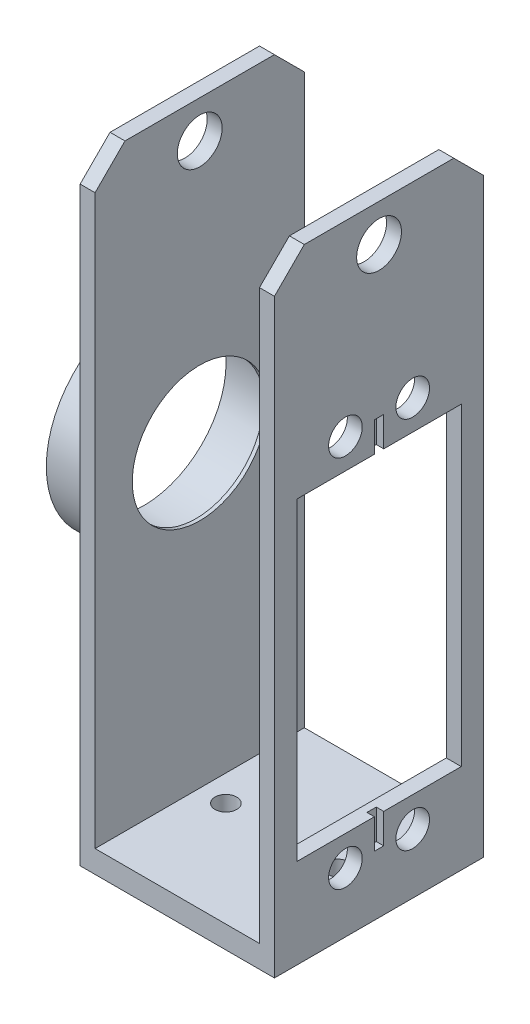
from build123d import *

# Parameters (mm, degrees)
SKETCH1_W               = 22
SKETCH1_H               = 28
BOSS_EXTRUDE1_DEPTH     = 3
SKETCH2_R               = 1.45
CUT_EXTRUDE1_DEPTH      = 4
SKETCH3_W               = 28
SKETCH3_H               = 80
SKETCH3_H_2             = 3
BOSS_EXTRUDE2_DEPTH     = 2
SKETCH4_R               = 2.25
SKETCH4_W               = 22
SKETCH4_H               = 42
CUT_EXTRUDE2_DEPTH      = 10
SKETCH5_R               = 11.025
CUT_EXTRUDE3_DEPTH      = 10
SKETCH6_R               = 11.025
SKETCH6_R_2             = 9.025
BOSS_EXTRUDE3_DEPTH     = 0.5
SKETCH7_R               = 13.025
SKETCH7_R_2             = 11.025
BOSS_EXTRUDE4_DEPTH     = 5.5
SKETCH9_W               = 1.25
SKETCH9_H               = 4
CUT_EXTRUDE5_DEPTH      = 1
SKETCH4_4_R             = 3
CUT_EXTRUDE6_DEPTH      = 30.5
CUT_EXTRUDE6_DEPTH_BACK = 3
CHAMFER1_SIZE           = 4


with BuildPart() as part:
    # Sketch1 → Boss-Extrude1 (new body)
    with BuildSketch(Plane(origin=(0, 0, 0), x_dir=(1, 0, 0), z_dir=(0, 1, 0))):
        Rectangle(SKETCH1_W, SKETCH1_H)
    extrude(amount=BOSS_EXTRUDE1_DEPTH)

    # Sketch2 → Cut-Extrude1 (cut, through all)
    with BuildSketch(Plane.XZ):
        with Locations(Location((-7.5, 0, 0), (0, 0, 270))):  # turned: the seam where the file's is
            Circle(SKETCH2_R)
        with Locations(Location((7.5, 0, 0), (0, 0, 270))):  # turned: the seam where the file's is
            Circle(SKETCH2_R)
    extrude(amount=-CUT_EXTRUDE1_DEPTH, mode=Mode.SUBTRACT)

    # Sketch3 → Boss-Extrude2 (add)
    with BuildSketch(Plane(origin=(11, 0, 0), x_dir=(0, 0, -1), z_dir=(1, 0, 0))):
        with Locations((0, 43)):
            Rectangle(SKETCH3_W, SKETCH3_H)
        with Locations((0, 1.5)):
            Rectangle(SKETCH3_W, SKETCH3_H_2)
    boss_extrude2 = extrude(amount=BOSS_EXTRUDE2_DEPTH)

    # Sketch4 → Cut-Extrude2 (cut)
    with BuildSketch(Plane.ZY.offset(-11)):
        with Locations((-4.5, 8)):
            Circle(SKETCH4_R)
        with Locations((4.5, 8)):
            Circle(SKETCH4_R)
        with Locations((4.5, 58)):
            Circle(SKETCH4_R)
        with Locations((-4.5, 58)):
            Circle(SKETCH4_R)
        with Locations((0, 33)):
            Rectangle(SKETCH4_W, SKETCH4_H)
    extrude(amount=-CUT_EXTRUDE2_DEPTH, mode=Mode.SUBTRACT)

    # Mirror1: Boss-Extrude2 across plane
    add(boss_extrude2.mirror(Plane(origin=(0, 0, 0), x_dir=(0, 0, 1), z_dir=(1, 0, 0))))

    # Sketch5 → Cut-Extrude3 (cut)
    with BuildSketch(Plane(origin=(-11, 0, 0), x_dir=(0, 0, -1), z_dir=(1, 0, 0))):
        with Locations((0, 43)):
            Circle(SKETCH5_R)
    extrude(amount=-CUT_EXTRUDE3_DEPTH, mode=Mode.SUBTRACT)

    # Sketch6 → Boss-Extrude3 (add)
    with BuildSketch(Plane(origin=(-11, 0, 0), x_dir=(0, 0, -1), z_dir=(1, 0, 0))):
        with Locations((0, 43)):
            Circle(SKETCH6_R)
        with Locations((0, 43)):
            Circle(SKETCH6_R_2, mode=Mode.SUBTRACT)
    extrude(amount=-BOSS_EXTRUDE3_DEPTH)

    # Sketch7 → Boss-Extrude4 (add)
    with BuildSketch(Plane.ZY.offset(13)):
        with Locations((0, 43)):
            Circle(SKETCH7_R)
        with Locations(Location((0, 43, 0), (0, 0, 180))):  # turned: the seam where the file's is
            Circle(SKETCH7_R_2, mode=Mode.SUBTRACT)
    extrude(amount=BOSS_EXTRUDE4_DEPTH)

    # Sketch9 → Cut-Extrude5 (cut)
    with BuildSketch(Plane(origin=(13, 0, 0), x_dir=(0, 0, -1), z_dir=(1, 0, 0))):
        with Locations((0, 56)):
            Rectangle(SKETCH9_W, SKETCH9_H)
        with Locations((0, 10)):
            Rectangle(SKETCH9_W, SKETCH9_H)
    extrude(amount=-CUT_EXTRUDE5_DEPTH, mode=Mode.SUBTRACT)

    # Sketch4_4 → Cut-Extrude6 (cut, two sides)
    with BuildSketch(Plane.ZY.offset(-11)) as cut_extrude6_sk:
        with Locations((0, 78)):
            Circle(SKETCH4_4_R)
    extrude(amount=CUT_EXTRUDE6_DEPTH, mode=Mode.SUBTRACT)
    extrude(cut_extrude6_sk.sketch, amount=-CUT_EXTRUDE6_DEPTH_BACK, mode=Mode.SUBTRACT)

    # Chamfer1
    chamfer1_edges = [part.edges().sort_by_distance(p)[0] for p in [
        (12, 83, 14),
        (12, 83, -14),
        (-12, 83, 14),
        (-12, 83, -14),
    ]]
    chamfer(chamfer1_edges, length=CHAMFER1_SIZE)


solid = part.part
